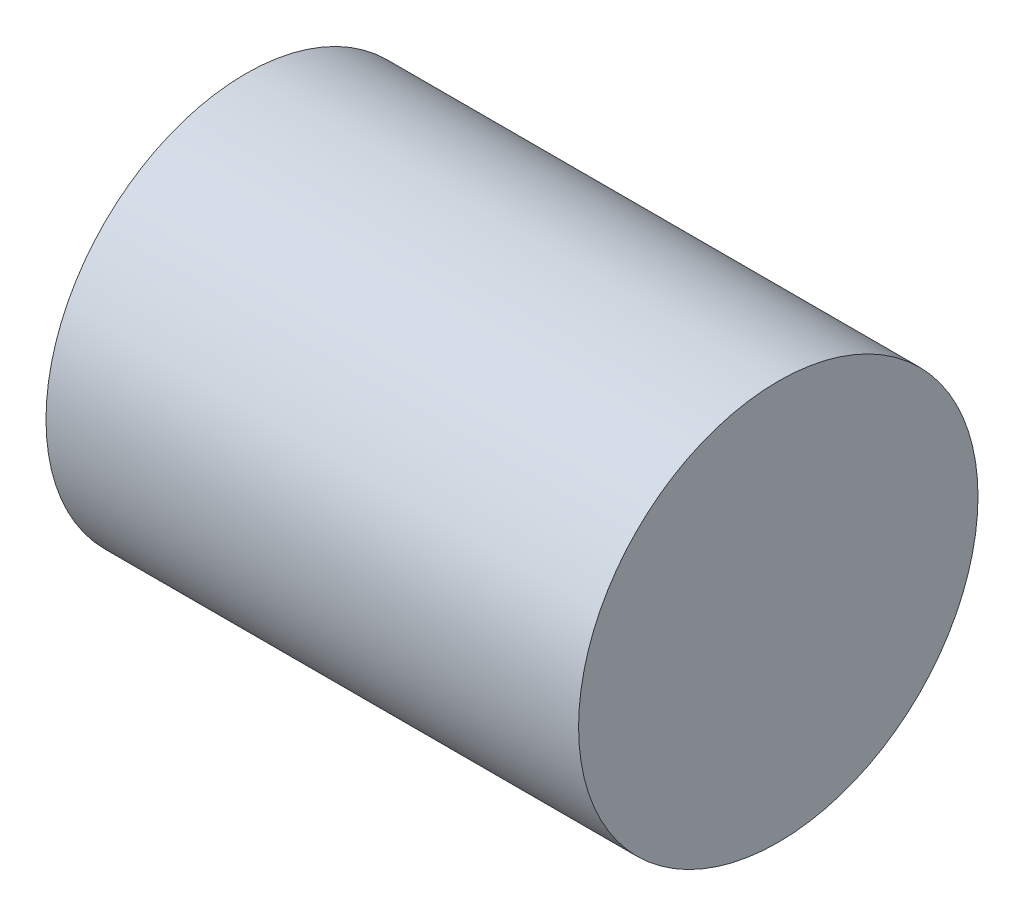
from build123d import *

# Parameters (mm, degrees)
SKETCH1_R           = 15
BOSS_EXTRUDE1_DEPTH = 40


with BuildPart() as part:
    # Sketch1 → Boss-Extrude1 (new body)
    with BuildSketch(Plane(origin=(0, 0, 0), x_dir=(0, 0, -1), z_dir=(1, 0, 0))):
        Circle(SKETCH1_R)
    extrude(amount=-BOSS_EXTRUDE1_DEPTH)


solid = part.part
